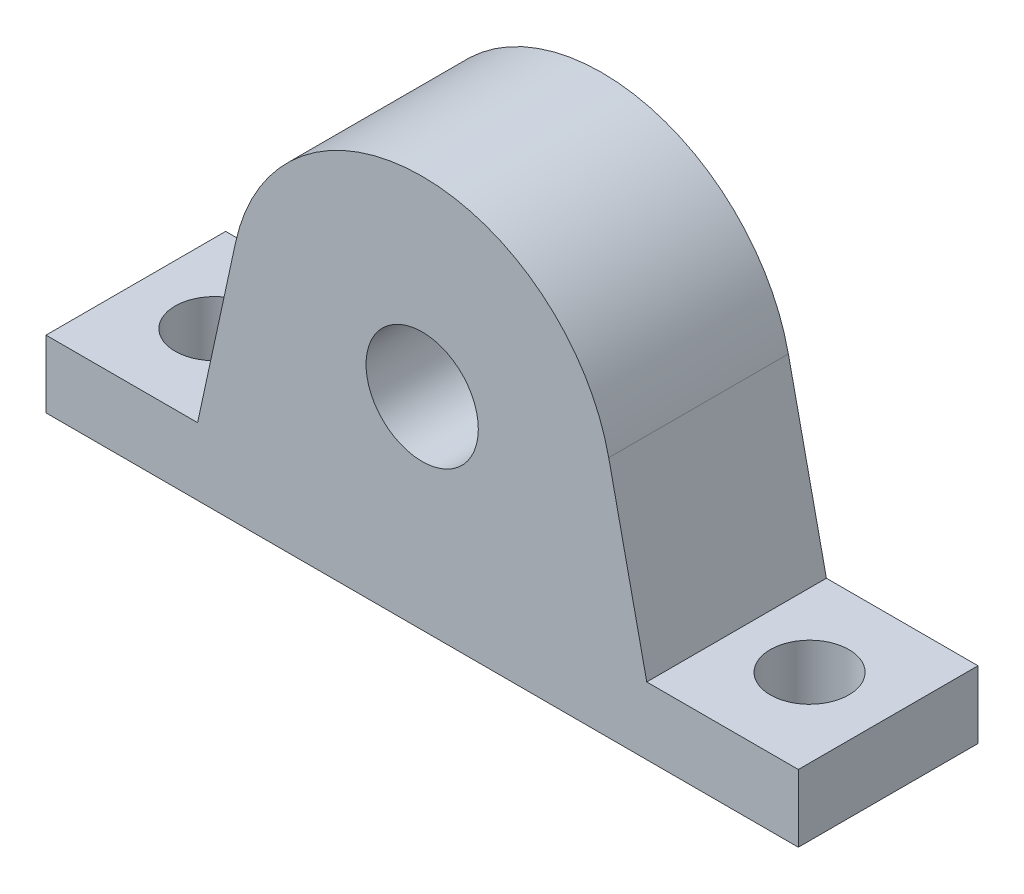
from build123d import *

# Parameters (mm, degrees)
EXTRUDE_1_DEPTH     = 8
SKETCH_2_R          = 3.5
CUT_EXTRUDE_1_DEPTH = 16
SKETCH_3_R          = 5
CUT_EXTRUDE_2_DEPTH = 16


with BuildPart() as part:
    # 草图1 → 凸台-拉伸1 (new body, symmetric)
    with BuildSketch(Plane.XY):
        with BuildLine():
            Line((-33.5, 0), (33.5, 0))
            Line((33.5, 0), (33.5, 6))
            Line((33.5, 6), (20, 6))
            Line((20, 6), (16.613269784, 21.605449639))
            ThreePointArc((16.613269784, 21.605449639), (0, 35), (-16.613269784, 21.605449639))
            Line((-16.613269784, 21.605449639), (-20, 6))
            Line((-20, 6), (-33.5, 6))
            Line((-33.5, 6), (-33.5, 0))
        make_face()
    extrude(amount=EXTRUDE_1_DEPTH, both=True)

    # 草图2 → 切除-拉伸1 (cut)
    with BuildSketch(Plane(origin=(0, 6, 0), x_dir=(1, 0, 0), z_dir=(0, 1, 0))):
        with Locations((-26.5, 0)):
            Circle(SKETCH_2_R)
        with Locations((26.5, 0)):
            Circle(SKETCH_2_R)
    extrude(amount=-CUT_EXTRUDE_1_DEPTH, mode=Mode.SUBTRACT)

    # 草图3 → 切除-拉伸2 (cut)
    with BuildSketch(Plane.XY.offset(8)):
        with Locations((0, 18)):
            Circle(SKETCH_3_R)
    extrude(amount=-CUT_EXTRUDE_2_DEPTH, mode=Mode.SUBTRACT)


solid = part.part
